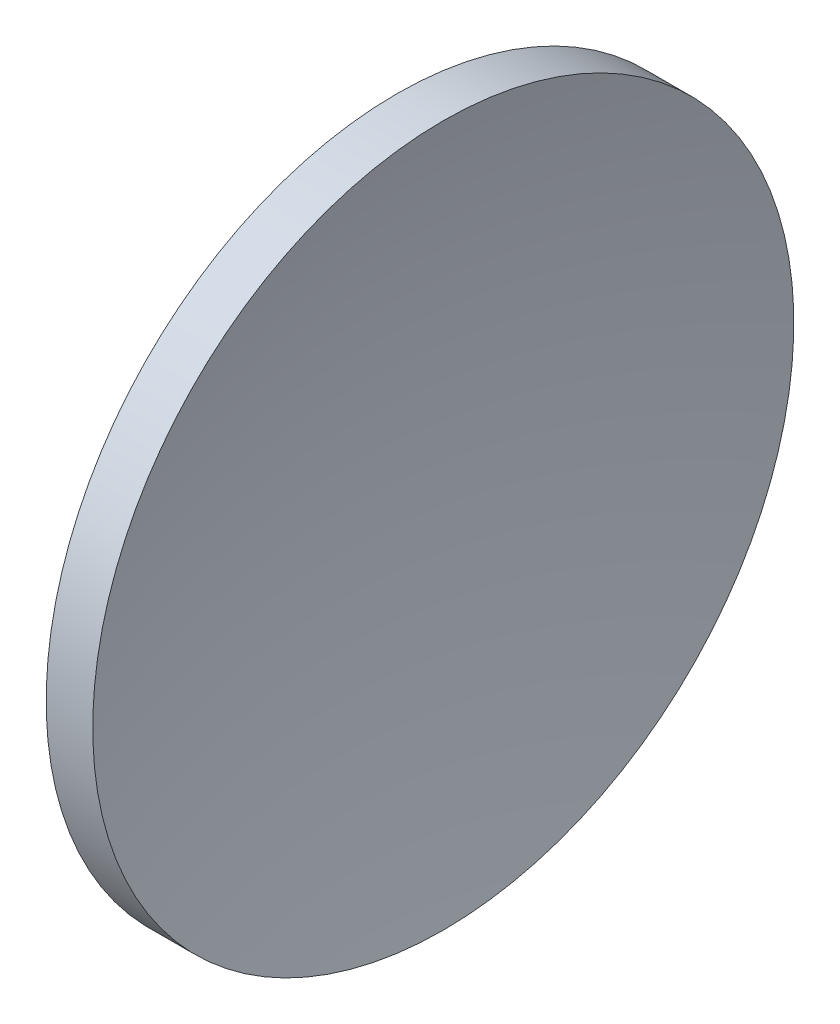
from build123d import *


with BuildPart() as part:
    # 草图1 → 旋转1 (revolve)
    with BuildSketch(Plane.XY):
        with BuildLine():
            Line((125.026767895, 77.716840471), (126.687206008, 77.716840471))
            ThreePointArc((126.687206008, 77.716840471), (125.498013023, 71.517055095), (125.099497836, 65.216840471))
            Line((125.099497836, 65.216840471), (122.599497836, 65.216840471))
            ThreePointArc((122.599497836, 65.216840471), (123.211930222, 71.583582965), (125.026767895, 77.716840471))
        make_face()
    revolve(axis=Axis((115.944491298, 65.216840471, 0), (1, 0, 0)))


solid = part.part
